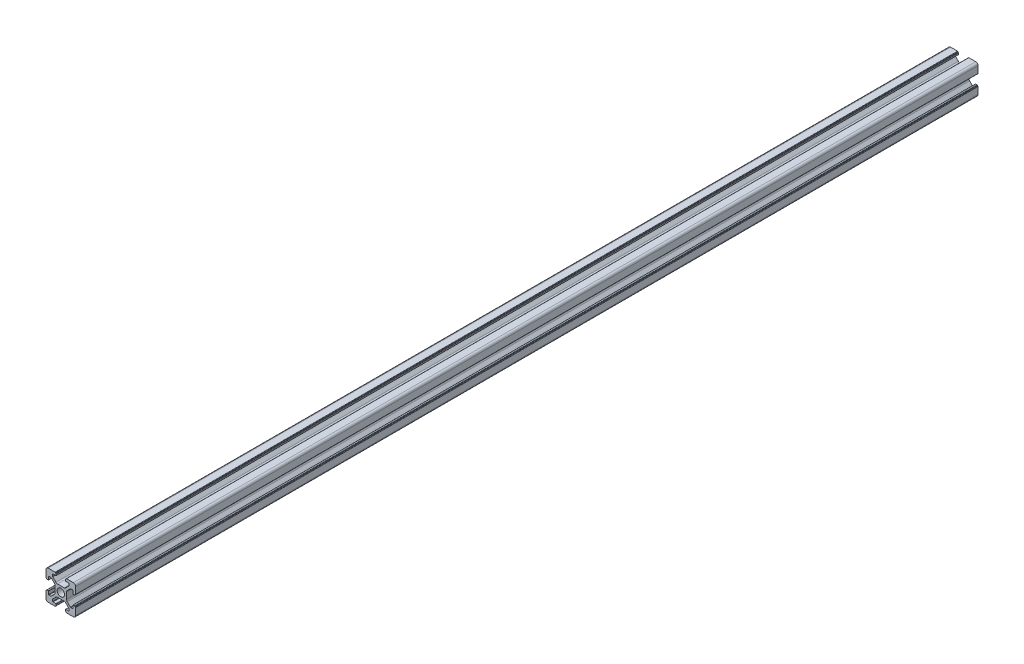
from build123d import *

# Parameters (mm, degrees)
SKETCH_1_R      = 2.5
EXTRUDE_1_DEPTH = 610


with BuildPart() as part:
    # 草图1 → 凸台-拉伸1 (new body)
    with BuildSketch(Plane.XY):
        with BuildLine():
            Line((-8.502261885, -10.002261885), (-3.85, -10.002261885))
            ThreePointArc((-3.85, -10.002261885), (-3.673223305, -9.929038581), (-3.6, -9.752261885))
            Line((-3.6, -9.752261885), (-3.6, -9.502261885))
            Line((-3.6, -9.502261885), (-3.35, -9.502261885))
            ThreePointArc((-3.35, -9.502261885), (-3.173223305, -9.429038581), (-3.1, -9.252261885))
            Line((-3.1, -9.252261885), (-3.1, -8.45))
            ThreePointArc((-3.1, -8.45), (-3.173223305, -8.273223305), (-3.35, -8.2))
            Line((-3.35, -8.2), (-5.25, -8.2))
            ThreePointArc((-5.25, -8.2), (-5.426776695, -8.126776695), (-5.5, -7.95))
            Line((-5.5, -7.95), (-5.5, -6.664213562))
            ThreePointArc((-5.5, -6.664213562), (-5.480969883, -6.568542704), (-5.426776695, -6.487436867))
            Line((-5.426776695, -6.487436867), (-3.278679656, -4.339339828))
            ThreePointArc((-3.278679656, -4.339339828), (-2.792044633, -4.014180701), (-2.218019485, -3.9))
            Line((-2.218019485, -3.9), (2.218019485, -3.9))
            ThreePointArc((2.218019485, -3.9), (2.792044633, -4.014180701), (3.278679656, -4.339339828))
            Line((3.278679656, -4.339339828), (5.426776695, -6.487436867))
            ThreePointArc((5.426776695, -6.487436867), (5.480969883, -6.568542704), (5.5, -6.664213562))
            Line((5.5, -6.664213562), (5.5, -7.95))
            ThreePointArc((5.5, -7.95), (5.426776695, -8.126776695), (5.25, -8.2))
            Line((5.25, -8.2), (3.35, -8.2))
            ThreePointArc((3.35, -8.2), (3.173223305, -8.273223305), (3.1, -8.45))
            Line((3.1, -8.45), (3.1, -9.252261885))
            ThreePointArc((3.1, -9.252261885), (3.173223305, -9.429038581), (3.35, -9.502261885))
            Line((3.35, -9.502261885), (3.6, -9.502261885))
            Line((3.6, -9.502261885), (3.6, -9.752261885))
            ThreePointArc((3.6, -9.752261885), (3.673223305, -9.929038581), (3.85, -10.002261885))
            Line((3.85, -10.002261885), (8.502261885, -10.002261885))
            ThreePointArc((8.502261885, -10.002261885), (9.562922057, -9.562922057), (10.002261885, -8.502261885))
            Line((10.002261885, -8.502261885), (10.002261885, -3.85))
            ThreePointArc((10.002261885, -3.85), (9.929038581, -3.673223305), (9.752261885, -3.6))
            Line((9.752261885, -3.6), (9.502261885, -3.6))
            Line((9.502261885, -3.6), (9.502261885, -3.35))
            ThreePointArc((9.502261885, -3.35), (9.429038581, -3.173223305), (9.252261885, -3.1))
            Line((9.252261885, -3.1), (8.45, -3.1))
            ThreePointArc((8.45, -3.1), (8.273223305, -3.173223305), (8.2, -3.35))
            Line((8.2, -3.35), (8.2, -5.25))
            ThreePointArc((8.2, -5.25), (8.126776695, -5.426776695), (7.95, -5.5))
            Line((7.95, -5.5), (6.664213562, -5.5))
            ThreePointArc((6.664213562, -5.5), (6.568542704, -5.480969883), (6.487436867, -5.426776695))
            Line((6.487436867, -5.426776695), (4.339339828, -3.278679656))
            ThreePointArc((4.339339828, -3.278679656), (4.014180701, -2.792044633), (3.9, -2.218019485))
            Line((3.9, -2.218019485), (3.9, 2.218019485))
            ThreePointArc((3.9, 2.218019485), (4.014180701, 2.792044633), (4.339339828, 3.278679656))
            Line((4.339339828, 3.278679656), (6.487436867, 5.426776695))
            ThreePointArc((6.487436867, 5.426776695), (6.568542704, 5.480969883), (6.664213562, 5.5))
            Line((6.664213562, 5.5), (7.95, 5.5))
            ThreePointArc((7.95, 5.5), (8.126776695, 5.426776695), (8.2, 5.25))
            Line((8.2, 5.25), (8.2, 3.35))
            ThreePointArc((8.2, 3.35), (8.273223305, 3.173223305), (8.45, 3.1))
            Line((8.45, 3.1), (9.252261885, 3.1))
            ThreePointArc((9.252261885, 3.1), (9.429038581, 3.173223305), (9.502261885, 3.35))
            Line((9.502261885, 3.35), (9.502261885, 3.6))
            Line((9.502261885, 3.6), (9.752261885, 3.6))
            ThreePointArc((9.752261885, 3.6), (9.929038581, 3.673223305), (10.002261885, 3.85))
            Line((10.002261885, 3.85), (10.002261885, 8.502261885))
            ThreePointArc((10.002261885, 8.502261885), (9.562922057, 9.562922057), (8.502261885, 10.002261885))
            Line((8.502261885, 10.002261885), (3.85, 10.002261885))
            ThreePointArc((3.85, 10.002261885), (3.673223305, 9.929038581), (3.6, 9.752261885))
            Line((3.6, 9.752261885), (3.6, 9.502261885))
            Line((3.6, 9.502261885), (3.35, 9.502261885))
            ThreePointArc((3.35, 9.502261885), (3.173223305, 9.429038581), (3.1, 9.252261885))
            Line((3.1, 9.252261885), (3.1, 8.45))
            ThreePointArc((3.1, 8.45), (3.173223305, 8.273223305), (3.35, 8.2))
            Line((3.35, 8.2), (5.25, 8.2))
            ThreePointArc((5.25, 8.2), (5.426776695, 8.126776695), (5.5, 7.95))
            Line((5.5, 7.95), (5.5, 6.664213562))
            ThreePointArc((5.5, 6.664213562), (5.480969883, 6.568542704), (5.426776695, 6.487436867))
            Line((5.426776695, 6.487436867), (3.278679656, 4.339339828))
            ThreePointArc((3.278679656, 4.339339828), (2.792044633, 4.014180701), (2.218019485, 3.9))
            Line((2.218019485, 3.9), (-2.218019485, 3.9))
            ThreePointArc((-2.218019485, 3.9), (-2.792044633, 4.014180701), (-3.278679656, 4.339339828))
            Line((-3.278679656, 4.339339828), (-5.426776695, 6.487436867))
            ThreePointArc((-5.426776695, 6.487436867), (-5.480969883, 6.568542704), (-5.5, 6.664213562))
            Line((-5.5, 6.664213562), (-5.5, 7.95))
            ThreePointArc((-5.5, 7.95), (-5.426776695, 8.126776695), (-5.25, 8.2))
            Line((-5.25, 8.2), (-3.35, 8.2))
            ThreePointArc((-3.35, 8.2), (-3.173223305, 8.273223305), (-3.1, 8.45))
            Line((-3.1, 8.45), (-3.1, 9.252261885))
            ThreePointArc((-3.1, 9.252261885), (-3.173223305, 9.429038581), (-3.35, 9.502261885))
            Line((-3.35, 9.502261885), (-3.6, 9.502261885))
            Line((-3.6, 9.502261885), (-3.6, 9.752261885))
            ThreePointArc((-3.6, 9.752261885), (-3.673223305, 9.929038581), (-3.85, 10.002261885))
            Line((-3.85, 10.002261885), (-8.502261885, 10.002261885))
            ThreePointArc((-8.502261885, 10.002261885), (-9.562922057, 9.562922057), (-10.002261885, 8.502261885))
            Line((-10.002261885, 8.502261885), (-10.002261885, 3.85))
            ThreePointArc((-10.002261885, 3.85), (-9.929038581, 3.673223305), (-9.752261885, 3.6))
            Line((-9.752261885, 3.6), (-9.502261885, 3.6))
            Line((-9.502261885, 3.6), (-9.502261885, 3.35))
            ThreePointArc((-9.502261885, 3.35), (-9.429038581, 3.173223305), (-9.252261885, 3.1))
            Line((-9.252261885, 3.1), (-8.45, 3.1))
            ThreePointArc((-8.45, 3.1), (-8.273223305, 3.173223305), (-8.2, 3.35))
            Line((-8.2, 3.35), (-8.2, 5.25))
            ThreePointArc((-8.2, 5.25), (-8.126776695, 5.426776695), (-7.95, 5.5))
            Line((-7.95, 5.5), (-6.664213562, 5.5))
            ThreePointArc((-6.664213562, 5.5), (-6.568542704, 5.480969883), (-6.487436867, 5.426776695))
            Line((-6.487436867, 5.426776695), (-4.339339828, 3.278679656))
            ThreePointArc((-4.339339828, 3.278679656), (-4.014180701, 2.792044633), (-3.9, 2.218019485))
            Line((-3.9, 2.218019485), (-3.9, -2.218019485))
            ThreePointArc((-3.9, -2.218019485), (-4.014180701, -2.792044633), (-4.339339828, -3.278679656))
            Line((-4.339339828, -3.278679656), (-6.487436867, -5.426776695))
            ThreePointArc((-6.487436867, -5.426776695), (-6.568542704, -5.480969883), (-6.664213562, -5.5))
            Line((-6.664213562, -5.5), (-7.95, -5.5))
            ThreePointArc((-7.95, -5.5), (-8.126776695, -5.426776695), (-8.2, -5.25))
            Line((-8.2, -5.25), (-8.2, -3.35))
            ThreePointArc((-8.2, -3.35), (-8.273223305, -3.173223305), (-8.45, -3.1))
            Line((-8.45, -3.1), (-9.252261885, -3.1))
            ThreePointArc((-9.252261885, -3.1), (-9.429038581, -3.173223305), (-9.502261885, -3.35))
            Line((-9.502261885, -3.35), (-9.502261885, -3.6))
            Line((-9.502261885, -3.6), (-9.752261885, -3.6))
            ThreePointArc((-9.752261885, -3.6), (-9.929038581, -3.673223305), (-10.002261885, -3.85))
            Line((-10.002261885, -3.85), (-10.002261885, -8.502261885))
            ThreePointArc((-10.002261885, -8.502261885), (-9.562922057, -9.562922057), (-8.502261885, -10.002261885))
        make_face()
        Circle(SKETCH_1_R, mode=Mode.SUBTRACT)
    extrude(amount=EXTRUDE_1_DEPTH)


solid = part.part
